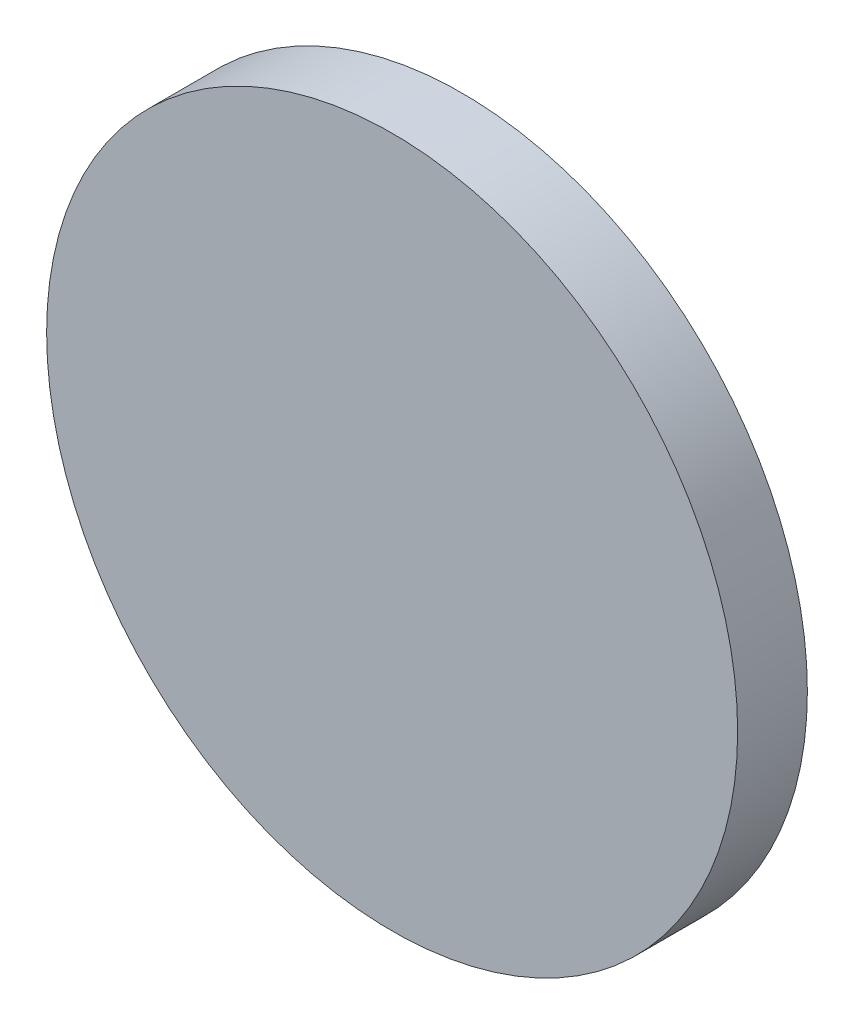
from build123d import *

# Parameters (mm, degrees)
SKETCH1_R           = 28.321
BOSS_EXTRUDE1_DEPTH = 5.715


with BuildPart() as part:
    # Sketch1 → Boss-Extrude1 (new body)
    with BuildSketch(Plane.XY):
        Circle(SKETCH1_R)
    extrude(amount=BOSS_EXTRUDE1_DEPTH)


solid = part.part
